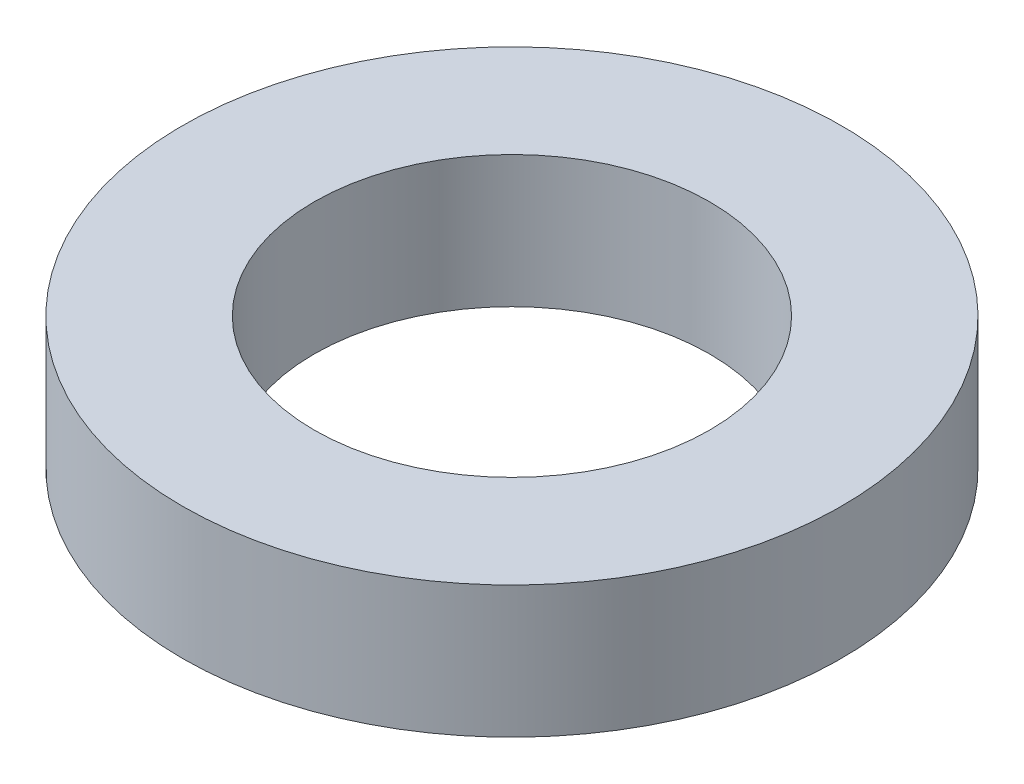
from build123d import *

# Parameters (mm, degrees)
SKETCH1_R           = 2.5
SKETCH1_R_2         = 1.5
BOSS_EXTRUDE1_DEPTH = 0.5


with BuildPart() as part:
    # Sketch1 → Boss-Extrude1 (new body, symmetric)
    with BuildSketch(Plane(origin=(0, 0, 0), x_dir=(1, 0, 0), z_dir=(0, 1, 0))):
        Circle(SKETCH1_R)
        Circle(SKETCH1_R_2, mode=Mode.SUBTRACT)
    extrude(amount=BOSS_EXTRUDE1_DEPTH, both=True)


solid = part.part
